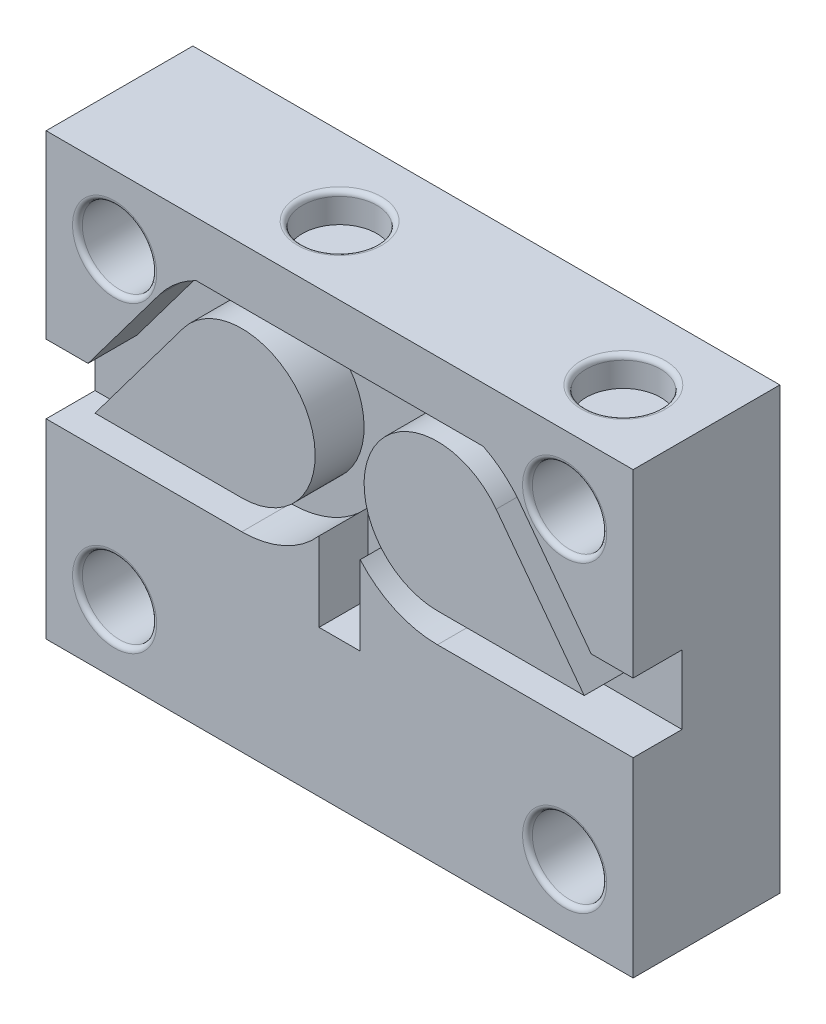
from build123d import *

# Parameters (mm, degrees)
SKETCH1_R             = 3.8
BOSS_EXTRUDE3_DEPTH   = 15
BOSS_EXTRUDE3_2_DEPTH = 15
BOSS_EXTRUDE3_3_DEPTH = 15
BOSS_EXTRUDE3_4_DEPTH = 15
BOSS_EXTRUDE4_DEPTH   = 10
SKETCH3_R             = 3.8
CUT_EXTRUDE2_DEPTH    = 3
FILLET2_R             = 0.5


with BuildPart() as part:
    # Sketch1 → Boss-Extrude3 (new body)
    with BuildSketch(Plane.XY):
        with BuildLine():
            Line((-30, -3), (-30, -22.5))
            Line((-30, -22.5), (30, -22.5))
            Line((30, -22.5), (30, -3))
            Line((30, -3), (10, -3))
            ThreePointArc((10, -3), (5.663072607, -2.062481937), (2.100611456, 0.582655088))
            Line((2.100611456, 0.582655088), (2.100327913, -7.512763105))
            Line((2.100327913, -7.512763105), (-2.100611456, -7.512763105))
            Line((-2.100611456, -7.512763105), (-2.100611456, 0.582655088))
            ThreePointArc((-2.100611456, 0.582655088), (-5.663072607, -2.062481937), (-10, -3))
            Line((-10, -3), (-30, -3))
        make_face()
        with Locations((-23, -15.5)):
            Circle(SKETCH1_R, mode=Mode.SUBTRACT)
        with Locations((23, -15.5)):
            Circle(SKETCH1_R, mode=Mode.SUBTRACT)
    extrude(amount=BOSS_EXTRUDE3_DEPTH)



with BuildPart() as body_2:
    # Sketch1 → Boss-Extrude3 2 (new body)
    with BuildSketch(Plane.XY):
        with BuildLine():
            Line((-30, 22.5), (-30, 4.047627556))
            Line((-30, 4.047627556), (-25.714279333, 4.047627556))
            Line((-25.714279333, 4.047627556), (-18.4, 13.8))
            ThreePointArc((-18.4, 13.8), (-16.720396487, 15.567606278), (-14.678379216, 16.900147228))
            Line((-14.678379216, 16.900147228), (14.678379216, 16.900147228))
            ThreePointArc((14.678379216, 16.900147228), (16.720396487, 15.567606278), (18.4, 13.8))
            Line((18.4, 13.8), (25.714279333, 4.047627556))
            Line((25.714279333, 4.047627556), (30, 4.047627556))
            Line((30, 4.047627556), (30, 22.5))
            Line((30, 22.5), (-30, 22.5))
        make_face()
        with Locations((-23, 15.5)):
            Circle(SKETCH1_R, mode=Mode.SUBTRACT)
        with Locations((23, 15.5)):
            Circle(SKETCH1_R, mode=Mode.SUBTRACT)
    extrude(amount=BOSS_EXTRUDE3_2_DEPTH)


with BuildPart() as body_3:
    # Sketch1 → Boss-Extrude3 3 (new body)
    with BuildSketch(Plane.XY):
        with BuildLine():
            Line((-25, 0), (-10, 0))
            ThreePointArc((-10, 0), (-3.291796068, 10.854101966), (-16, 12))
            Line((-16, 12), (-25, 0))
        make_face()
    extrude(amount=BOSS_EXTRUDE3_3_DEPTH)


with BuildPart() as body_4:
    # Sketch1 → Boss-Extrude3 4 (new body)
    with BuildSketch(Plane.XY):
        with BuildLine():
            Line((10, 0), (25, 0))
            Line((25, 0), (16, 12))
            ThreePointArc((16, 12), (3.291796068, 10.854101966), (10, 0))
        make_face()
    extrude(amount=BOSS_EXTRUDE3_4_DEPTH)


with BuildPart() as part_1:
    add(part.part)

    add(body_2.part)  # Boss-Extrude4 merges body 2

    add(body_3.part)  # Boss-Extrude4 merges body 3

    add(body_4.part)  # Boss-Extrude4 merges body 4
    # Sketch1_10 → Boss-Extrude4 (add)
    with BuildSketch(Plane.XY):
        with BuildLine():
            Line((-30, 4.047627556), (-30, -3))
            Line((-30, -3), (-10, -3))
            ThreePointArc((-10, -3), (-5.663072607, -2.062481937), (-2.100611456, 0.582655088))
            Line((-2.100611456, 0.582655088), (-2.100611456, -7.512763105))
            Line((-2.100611456, -7.512763105), (2.100327913, -7.512763105))
            Line((2.100327913, -7.512763105), (2.100611456, 0.582655088))
            ThreePointArc((2.100611456, 0.582655088), (5.663072607, -2.062481937), (10, -3))
            Line((10, -3), (30, -3))
            Line((30, -3), (30, 4.047627556))
            Line((30, 4.047627556), (25.714279333, 4.047627556))
            Line((25.714279333, 4.047627556), (18.4, 13.8))
            ThreePointArc((18.4, 13.8), (16.720396487, 15.567606278), (14.678379216, 16.900147228))
            Line((14.678379216, 16.900147228), (-14.678379216, 16.900147228))
            ThreePointArc((-14.678379216, 16.900147228), (-16.720396487, 15.567606278), (-18.4, 13.8))
            Line((-18.4, 13.8), (-25.714279333, 4.047627556))
            Line((-25.714279333, 4.047627556), (-30, 4.047627556))
        make_face()
        with BuildLine():
            ThreePointArc((-2.5, 7.5), (-4.696699141, 2.196699141), (-10, 0))
            Line((-10, 0), (-25, 0))
            Line((-25, 0), (-16, 12))
            ThreePointArc((-16, 12), (-7.628291755, 14.615124735), (-2.5, 7.5))
        make_face(mode=Mode.SUBTRACT)
        with BuildLine():
            Line((16, 12), (25, 0))
            Line((25, 0), (10, 0))
            ThreePointArc((10, 0), (3.291796068, 10.854101966), (16, 12))
        make_face(mode=Mode.SUBTRACT)
    extrude(amount=BOSS_EXTRUDE4_DEPTH)

    # Sketch3 → Cut-Extrude2 (cut)
    with BuildSketch(Plane(origin=(0, 22.5, 0), x_dir=(1, 0, 0), z_dir=(0, 1, 0))):
        with Locations((22, -8)):
            Circle(SKETCH3_R)
        with Locations((-7, -8)):
            Circle(SKETCH3_R)
    extrude(amount=-CUT_EXTRUDE2_DEPTH, mode=Mode.SUBTRACT)

    # Fillet2
    fillet2_edges = [part_1.edges().sort_by_distance(p)[0] for p in [
        (19.2, 15.5, 0),
        (19.2, -15.5, 0),
        (-26.8, 15.5, 0),
        (-26.8, -15.5, 0),
        (-26.8, 15.5, 15),
        (-26.8, -15.5, 15),
        (19.2, -15.5, 15),
        (19.2, 15.5, 15),
        (18.2, 22.5, 8),
        (-10.8, 22.5, 8),
    ]]
    fillet(fillet2_edges, radius=FILLET2_R)


solid = part_1.part
